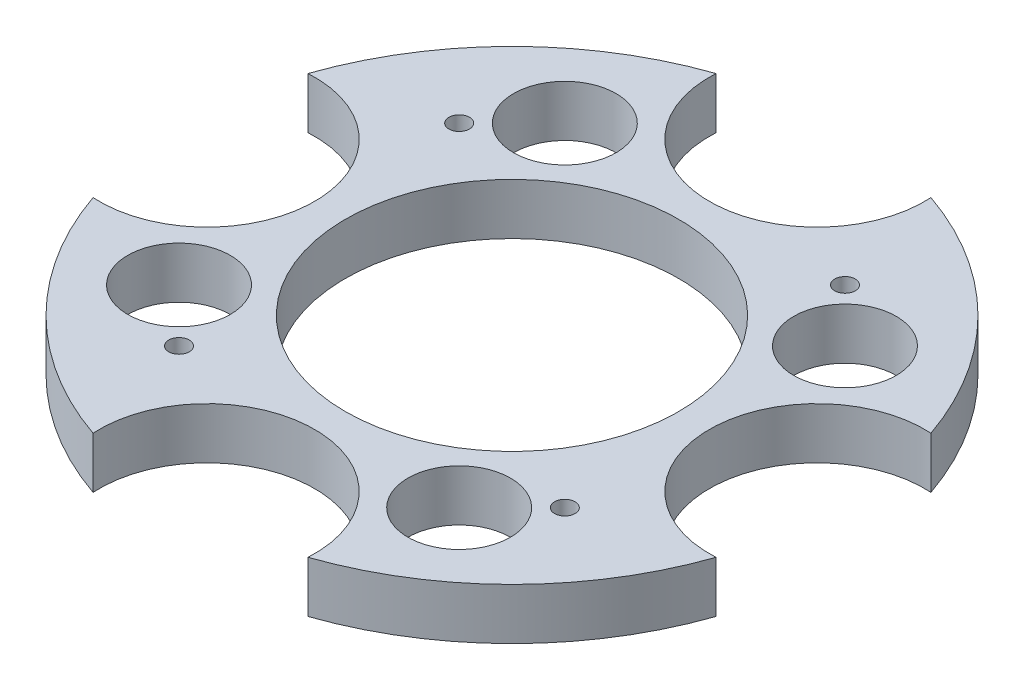
from build123d import *

# Parameters (mm, degrees)
SKETCH1_R           = 32.135
SKETCH1_R_2         = 16.25
BOSS_EXTRUDE1_DEPTH = 2.5
SKETCH2_R           = 10.5
CUT_EXTRUDE1_DEPTH  = 6
CIRPATTERN1_COUNT   = 4
BOSS_EXTRUDE2_DEPTH = 5
CIRPATTERN2_COUNT   = 4
SKETCH4_R           = 5
SKETCH4_R_2         = 1
CUT_EXTRUDE2_DEPTH  = 6
CIRPATTERN3_COUNT   = 4
SKETCH5_R           = 43.25
SKETCH5_R_2         = 32.135
CUT_EXTRUDE3_DEPTH  = 6


with BuildPart() as part:
    # Sketch1 → Boss-Extrude1 (new body, symmetric)
    with BuildSketch(Plane(origin=(0, 0, 0), x_dir=(1, 0, 0), z_dir=(0, 1, 0))):
        Circle(SKETCH1_R)
        Circle(SKETCH1_R_2, mode=Mode.SUBTRACT)
    extrude(amount=BOSS_EXTRUDE1_DEPTH, both=True)

    # Sketch2 → Cut-Extrude1 (cut, through all)
    with BuildSketch(Plane(origin=(0, 2.5, 0), x_dir=(1, 0, 0), z_dir=(0, 1, 0))):
        with Locations((0, 29.75)):
            Circle(SKETCH2_R)
    cut_extrude1 = extrude(amount=-CUT_EXTRUDE1_DEPTH, mode=Mode.SUBTRACT)

    # CirPattern1: Cut-Extrude1 ×4 about axis
    cirpattern1_axis = Axis((0, 0, 0), (0, 1, 0))
    for i in range(1, CIRPATTERN1_COUNT):
        add(cut_extrude1.rotate(cirpattern1_axis, i * 360 / CIRPATTERN1_COUNT), mode=Mode.SUBTRACT)

    # Sketch3 → Boss-Extrude2 (add, through all)
    with BuildSketch(Plane(origin=(0, 2.5, 0), x_dir=(1, 0, 0), z_dir=(0, 1, 0))):
        with BuildLine():
            ThreePointArc((-10.481223396, 30.377659244), (0, 40.25), (10.481223396, 30.377659244))
            ThreePointArc((10.481223396, 30.377659244), (15.068921739, 28.382843808), (19.29142779, 25.700175852))
            ThreePointArc((19.29142779, 25.700175852), (15.324886367, 29.659432114), (12.612593732, 34.563780152))
            ThreePointArc((12.612593732, 34.563780152), (0, 43.25), (-12.612593732, 34.563780152))
            ThreePointArc((-12.612593732, 34.563780152), (-15.324886367, 29.659432114), (-19.29142779, 25.700175852))
            ThreePointArc((-19.29142779, 25.700175852), (-15.068921739, 28.382843808), (-10.481223396, 30.377659244))
        make_face()
    boss_extrude2 = extrude(amount=-BOSS_EXTRUDE2_DEPTH)

    # CirPattern2: Boss-Extrude2 ×4 about axis
    cirpattern2_axis = Axis((0, 0, 0), (0, 1, 0))
    for i in range(1, CIRPATTERN2_COUNT):
        add(boss_extrude2.rotate(cirpattern2_axis, i * 360 / CIRPATTERN2_COUNT))

    # Sketch4 → Cut-Extrude2 (cut, through all)
    with BuildSketch(Plane(origin=(0, 2.5, 0), x_dir=(1, 0, 0), z_dir=(0, 1, 0))):
        with Locations((-13.66135361, 18.81302521)):
            Circle(SKETCH4_R)
        with Locations((13.66135361, 18.81302521)):
            Circle(SKETCH4_R_2)
    cut_extrude2 = extrude(amount=-CUT_EXTRUDE2_DEPTH, mode=Mode.SUBTRACT)

    # CirPattern3: Cut-Extrude2 ×4 about axis
    cirpattern3_axis = Axis((0, 0, 0), (0, 1, 0))
    for i in range(1, CIRPATTERN3_COUNT):
        add(cut_extrude2.rotate(cirpattern3_axis, i * 360 / CIRPATTERN3_COUNT), mode=Mode.SUBTRACT)

    # Sketch5 → Cut-Extrude3 (cut, through all)
    with BuildSketch(Plane(origin=(0, 2.5, 0), x_dir=(1, 0, 0), z_dir=(0, 1, 0))):
        Circle(SKETCH5_R)
        Circle(SKETCH5_R_2, mode=Mode.SUBTRACT)
    extrude(amount=-CUT_EXTRUDE3_DEPTH, mode=Mode.SUBTRACT)


solid = part.part
